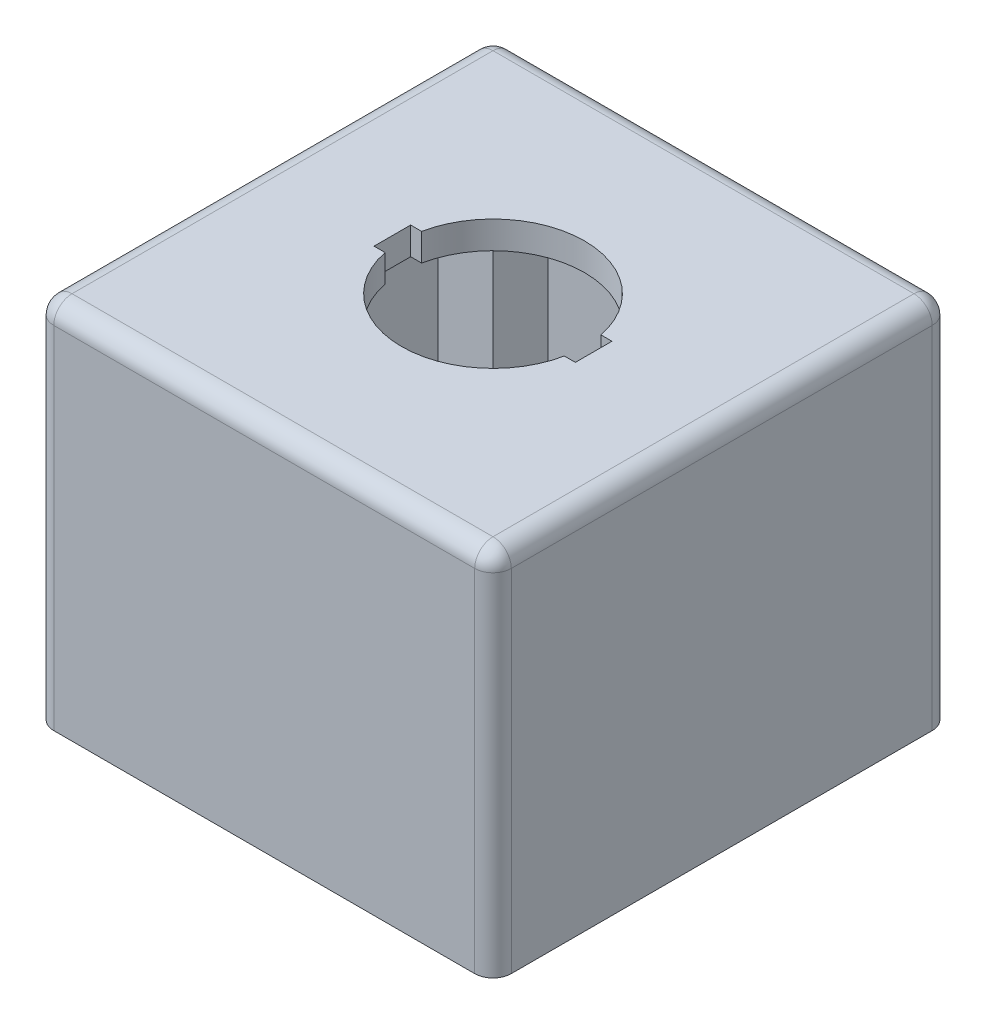
from build123d import *

# Parameters (mm, degrees)
SKETCH1_W           = 50
SKETCH1_H           = 50
BOSS_EXTRUDE1_DEPTH = 50
SHELL1_T            = -3
FILLET1_R           = 2
SKETCH3_W           = 6
SKETCH3_H           = 6
BOSS_EXTRUDE2_DEPTH = 47
SKETCH4_R           = 1.25
CUT_EXTRUDE1_DEPTH  = 25
SKETCH5_R           = 10
CUT_EXTRUDE2_DEPTH  = 51
SKETCH8_W           = 22
SKETCH8_H           = 4
CUT_EXTRUDE4_DEPTH  = 51
SKETCH9_W           = 50
SKETCH9_H           = 9.65
CUT_EXTRUDE5_DEPTH  = 51


with BuildPart() as part:
    # Sketch1 → Boss-Extrude1 (new body)
    with BuildSketch(Plane(origin=(0, 0, 0), x_dir=(1, 0, 0), z_dir=(0, 1, 0))):
        Rectangle(SKETCH1_W, SKETCH1_H)
    extrude(amount=BOSS_EXTRUDE1_DEPTH)

    # Shell1
    shell1_openings = [part.faces().sort_by_distance(p)[0] for p in [
        (0, 0, 0),
    ]]
    offset(amount=SHELL1_T, openings=shell1_openings, kind=Kind.INTERSECTION)

    # Fillet1
    fillet1_edges = [part.edges().sort_by_distance(p)[0] for p in [
        (-25, 50, 0),
        (0, 50, 25),
        (25, 50, 0),
        (0, 50, -25),
        (25, 25, 25),
        (-25, 25, 25),
        (-25, 25, -25),
        (25, 25, -25),
    ]]
    fillet(fillet1_edges, radius=FILLET1_R)

    # Sketch3 → Boss-Extrude2 (add)
    with BuildSketch(Plane.XZ.offset(-47)):
        with Locations((19, 19)):
            Rectangle(SKETCH3_W, SKETCH3_H)
        with Locations((-19, 19)):
            Rectangle(SKETCH3_W, SKETCH3_H)
        with Locations((19, -19)):
            Rectangle(SKETCH3_W, SKETCH3_H)
        with Locations((-19, -19)):
            Rectangle(SKETCH3_W, SKETCH3_H)
    extrude(amount=BOSS_EXTRUDE2_DEPTH)

    # Sketch4 → Cut-Extrude1 (cut)
    with BuildSketch(Plane.XZ):
        with Locations((-19, 19)):
            Circle(SKETCH4_R)
        with Locations((19, 19)):
            Circle(SKETCH4_R)
        with Locations((19, -19)):
            Circle(SKETCH4_R)
        with Locations((-19, -19)):
            Circle(SKETCH4_R)
    extrude(amount=-CUT_EXTRUDE1_DEPTH, mode=Mode.SUBTRACT)

    # Sketch5 → Cut-Extrude2 (cut, through all)
    with BuildSketch(Plane(origin=(0, 50, 0), x_dir=(1, 0, 0), z_dir=(0, 1, 0))):
        Circle(SKETCH5_R)
    extrude(amount=-CUT_EXTRUDE2_DEPTH, mode=Mode.SUBTRACT)

    # Sketch8 → Cut-Extrude4 (cut, through all)
    with BuildSketch(Plane(origin=(0, 50, 0), x_dir=(1, 0, 0), z_dir=(0, 1, 0))):
        Rectangle(SKETCH8_W, SKETCH8_H)
    extrude(amount=-CUT_EXTRUDE4_DEPTH, mode=Mode.SUBTRACT)

    # Sketch9 → Cut-Extrude5 (cut, through all)
    with BuildSketch(Plane(origin=(0, 0, -25), x_dir=(-1, 0, 0), z_dir=(0, 0, -1))):
        with Locations((0, 4.825)):
            Rectangle(SKETCH9_W, SKETCH9_H)
    extrude(amount=-CUT_EXTRUDE5_DEPTH, mode=Mode.SUBTRACT)


solid = part.part
